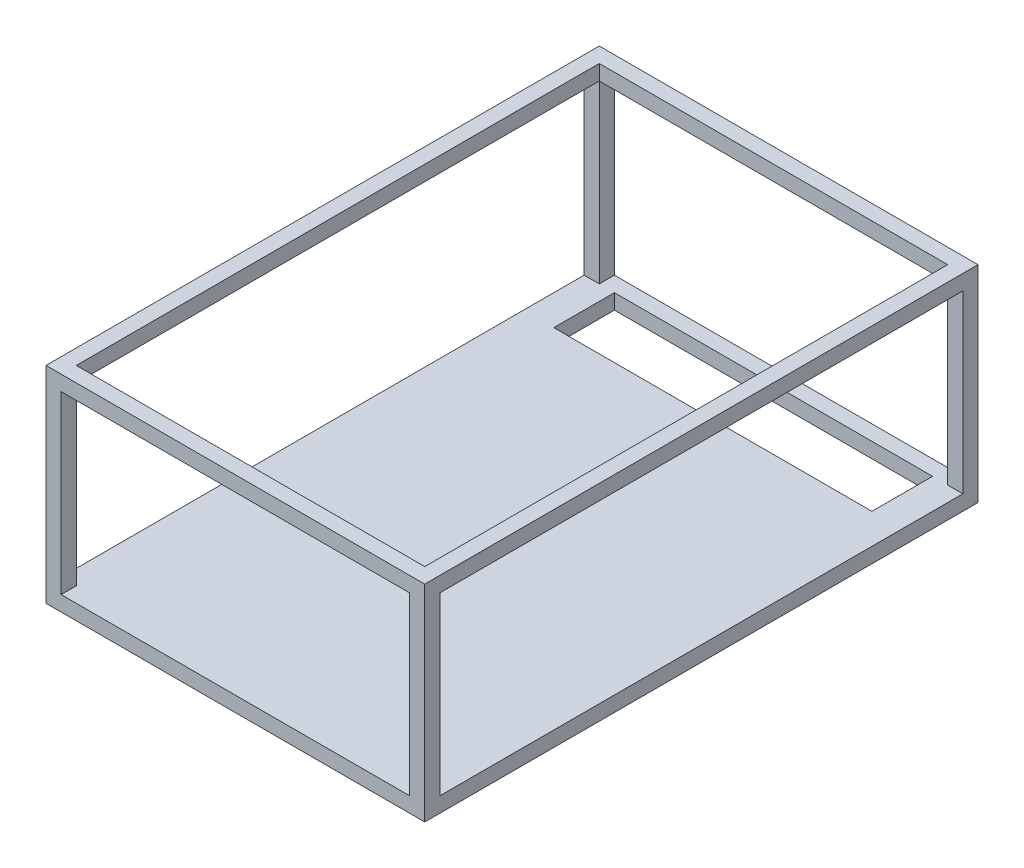
from build123d import *

# Parameters (mm, degrees)
SKETCH1_W           = 125
SKETCH1_H           = 68
BOSS_EXTRUDE1_DEPTH = 182.6
SKETCH2_W           = 172.6
SKETCH2_H           = 58
CUT_EXTRUDE1_DEPTH  = 126
SKETCH3_W           = 115
SKETCH3_H           = 58
CUT_EXTRUDE2_DEPTH  = 183.6
SKETCH4_W           = 115
SKETCH4_H           = 172.6
CUT_EXTRUDE3_DEPTH  = 63
SKETCH5_W           = 105
SKETCH5_H           = 20
CUT_EXTRUDE4_DEPTH  = 6


with BuildPart() as part:
    # Sketch1 → Boss-Extrude1 (new body)
    with BuildSketch(Plane.XY):
        Rectangle(SKETCH1_W, SKETCH1_H)
    extrude(amount=BOSS_EXTRUDE1_DEPTH)

    # Sketch2 → Cut-Extrude1 (cut, through all)
    with BuildSketch(Plane(origin=(62.5, 0, 0), x_dir=(0, 0, -1), z_dir=(1, 0, 0))):
        with Locations((-91.3, 0)):
            Rectangle(SKETCH2_W, SKETCH2_H)
    extrude(amount=-CUT_EXTRUDE1_DEPTH, mode=Mode.SUBTRACT)

    # Sketch3 → Cut-Extrude2 (cut, through all)
    with BuildSketch(Plane(origin=(0, 0, 0), x_dir=(-1, 0, 0), z_dir=(0, 0, -1))):
        Rectangle(SKETCH3_W, SKETCH3_H)
    extrude(amount=-CUT_EXTRUDE2_DEPTH, mode=Mode.SUBTRACT)

    # Sketch4 → Cut-Extrude3 (cut)
    with BuildSketch(Plane(origin=(0, 34, 0), x_dir=(1, 0, 0), z_dir=(0, 1, 0))):
        with Locations((0, -91.3)):
            Rectangle(SKETCH4_W, SKETCH4_H)
    extrude(amount=-CUT_EXTRUDE3_DEPTH, mode=Mode.SUBTRACT)

    # Sketch5 → Cut-Extrude4 (cut, through all)
    with BuildSketch(Plane(origin=(0, -29, 0), x_dir=(1, 0, 0), z_dir=(0, 1, 0))):
        with Locations((0, -15)):
            Rectangle(SKETCH5_W, SKETCH5_H)
    extrude(amount=-CUT_EXTRUDE4_DEPTH, mode=Mode.SUBTRACT)


solid = part.part
